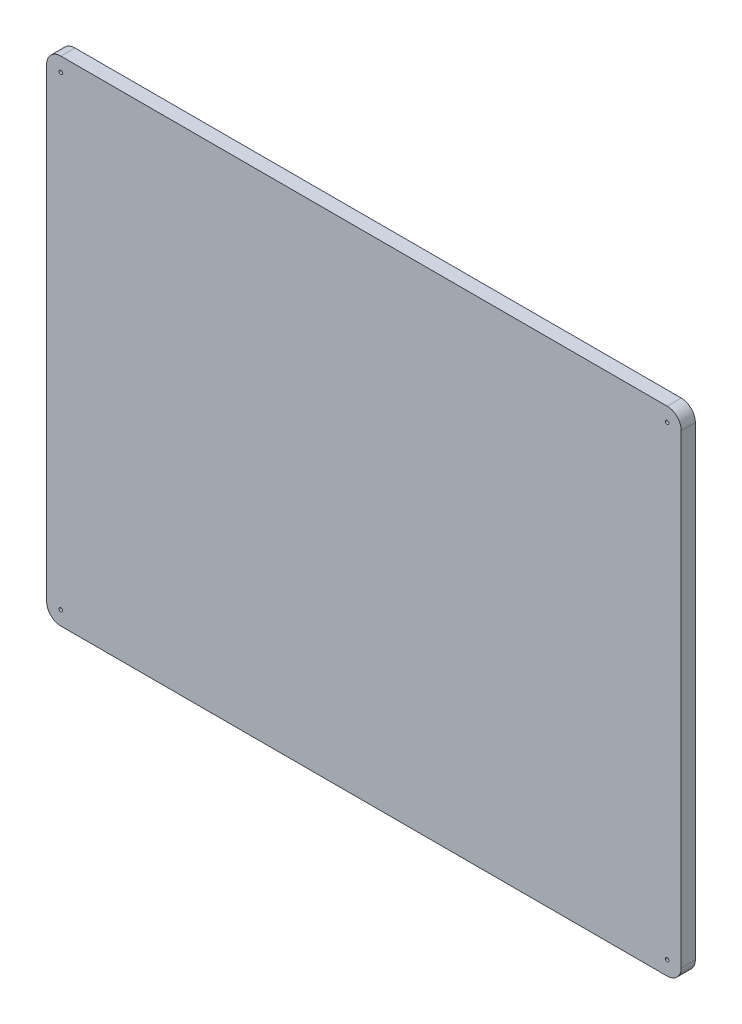
from build123d import *

# Parameters (mm, degrees)
SKETCH1_W           = 114.3
SKETCH1_H           = 88.9
BOSS_EXTRUDE1_DEPTH = 2.54
FILLET1_R           = 2.54
CUT_EXTRUDE1_REACH  = 4.54
SKETCH2_R           = 0.3175


with BuildPart() as part:
    # Sketch1 → Boss-Extrude1 (new body)
    with BuildSketch(Plane.XY):
        Rectangle(SKETCH1_W, SKETCH1_H)
    extrude(amount=BOSS_EXTRUDE1_DEPTH)

    # Fillet1
    fillet1_edges = [part.edges().sort_by_distance(p)[0] for p in [
        (57.15, -44.45, 1.27),
        (-57.15, -44.45, 1.27),
        (-57.15, 44.45, 1.27),
        (57.15, 44.45, 1.27),
    ]]
    fillet(fillet1_edges, radius=FILLET1_R)

    # Sketch2 → Cut-Extrude1 (cut, up to next)
    with BuildSketch(Plane.XY.offset(2.54), mode=Mode.PRIVATE) as cut_extrude1_sk1:
        with Locations((-54.61, 41.91)):
            Circle(SKETCH2_R)
    cut_extrude1_tool1 = extrude(cut_extrude1_sk1.sketch, amount=-CUT_EXTRUDE1_REACH, mode=Mode.PRIVATE) & part.part
    add(cut_extrude1_tool1.solids().sort_by_distance((-54.61, 41.91, 2.54))[0], mode=Mode.SUBTRACT)
    # Sketch2 → Cut-Extrude1 (cut, up to next)
    with BuildSketch(Plane.XY.offset(2.54), mode=Mode.PRIVATE) as cut_extrude1_sk2:
        with Locations((54.61, 41.91)):
            Circle(SKETCH2_R)
    cut_extrude1_tool2 = extrude(cut_extrude1_sk2.sketch, amount=-CUT_EXTRUDE1_REACH, mode=Mode.PRIVATE) & part.part
    add(cut_extrude1_tool2.solids().sort_by_distance((54.61, 41.91, 2.54))[0], mode=Mode.SUBTRACT)
    # Sketch2 → Cut-Extrude1 (cut, up to next)
    with BuildSketch(Plane.XY.offset(2.54), mode=Mode.PRIVATE) as cut_extrude1_sk3:
        with Locations((54.61, -41.91)):
            Circle(SKETCH2_R)
    cut_extrude1_tool3 = extrude(cut_extrude1_sk3.sketch, amount=-CUT_EXTRUDE1_REACH, mode=Mode.PRIVATE) & part.part
    add(cut_extrude1_tool3.solids().sort_by_distance((54.61, -41.91, 2.54))[0], mode=Mode.SUBTRACT)
    # Sketch2 → Cut-Extrude1 (cut, up to next)
    with BuildSketch(Plane.XY.offset(2.54), mode=Mode.PRIVATE) as cut_extrude1_sk4:
        with Locations((-54.61, -41.91)):
            Circle(SKETCH2_R)
    cut_extrude1_tool4 = extrude(cut_extrude1_sk4.sketch, amount=-CUT_EXTRUDE1_REACH, mode=Mode.PRIVATE) & part.part
    add(cut_extrude1_tool4.solids().sort_by_distance((-54.61, -41.91, 2.54))[0], mode=Mode.SUBTRACT)


solid = part.part
